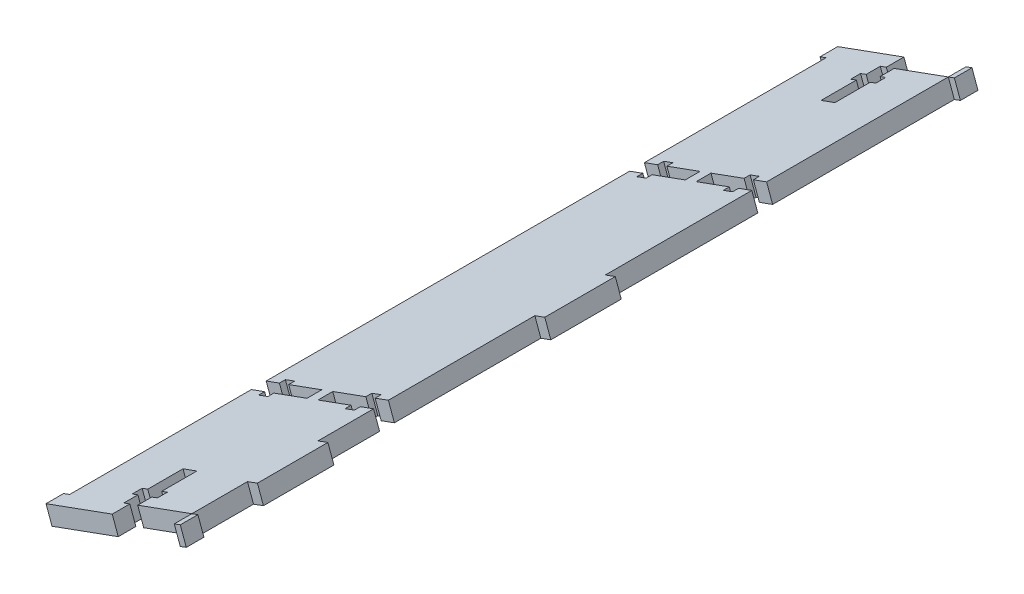
from build123d import *

# Parameters (mm, degrees)
BOSS_EXTRUDE1_DEPTH = 214.686455
CUT_EXTRUDE3_DEPTH  = 17.853621588
SKETCH5_W           = 20
SKETCH5_H           = 5
SKETCH5_W_2         = 1.823440518
SKETCH5_W_3         = 3
SKETCH5_H_2         = 20
BOSS_EXTRUDE2_DEPTH = 5


with BuildPart() as part:
    # Sketch2 → Boss-Extrude1 (new body)
    with BuildSketch(Plane.XY.offset(4.949356739)):
        Polygon((-52.961538618, -36.862052104), (-51.252736373, -41.56098761), (-85.936742732, -54.174080058), (-87.645544977, -49.475144552), align=None)
    extrude(amount=BOSS_EXTRUDE1_DEPTH)

    # Sketch4 → Cut-Extrude3 (cut, through all)
    with BuildSketch(Plane(origin=(7.362313595, -20.245196221, 0), x_dir=(-0.939787101, -0.341760449, 0), z_dir=(0.341760449, -0.939787101, 0))):
        Polygon((78.723681295, -4.949356739), (82.923681295, -4.949356739), (82.923681295, -8.949356739), (84.623681295, -8.949356739), (84.623681295, -11.749356739), (82.923681295, -11.749356739), (82.923681295, -21.749356739), (78.723681295, -21.749356739), (78.723681295, -11.749356739), (77.023681295, -11.749356739), (77.023681295, -8.949356739), (78.723681295, -8.949356739), align=None)
        Polygon((62.37056233, -60.720970532), (62.37056233, -56.520970532), (66.37056233, -56.520970532), (66.37056233, -54.820970532), (69.17056233, -54.820970532), (69.17056233, -56.520970532), (79.17056233, -56.520970532), (79.17056233, -60.720970532), (69.17056233, -60.720970532), (69.17056233, -62.420970532), (66.37056233, -62.420970532), (66.37056233, -60.720970532), align=None)
        Polygon((82.923681295, -219.635811913), (78.723681295, -219.635811913), (78.723681295, -215.635811913), (77.023681295, -215.635811913), (77.023681295, -212.835811913), (78.723681295, -212.835811913), (78.723681295, -202.835811913), (82.923681295, -202.835811913), (82.923681295, -212.835811913), (84.623681295, -212.835811913), (84.623681295, -215.635811913), (82.923681295, -215.635811913), align=None)
        Polygon((66.37056233, -168.064198119), (66.37056233, -169.764198119), (69.17056233, -169.764198119), (69.17056233, -168.064198119), (79.17056233, -168.064198119), (79.17056233, -163.864198119), (69.17056233, -163.864198119), (69.17056233, -162.164198119), (66.37056233, -162.164198119), (66.37056233, -163.864198119), (62.37056233, -163.864198119), (62.37056233, -168.064198119), align=None)
        Polygon((99.276800261, -163.864198119), (99.276800261, -168.064198119), (95.276800261, -168.064198119), (95.276800261, -169.764198119), (92.476800261, -169.764198119), (92.476800261, -168.064198119), (82.476800261, -168.064198119), (82.476800261, -163.864198119), (92.476800261, -163.864198119), (92.476800261, -162.164198119), (95.276800261, -162.164198119), (95.276800261, -163.864198119), align=None)
        Polygon((95.276800261, -56.520970532), (95.276800261, -54.820970532), (92.476800261, -54.820970532), (92.476800261, -56.520970532), (82.476800261, -56.520970532), (82.476800261, -60.720970532), (92.476800261, -60.720970532), (92.476800261, -62.420970532), (95.276800261, -62.420970532), (95.276800261, -60.720970532), (99.276800261, -60.720970532), (99.276800261, -56.520970532), align=None)
    extrude(amount=-CUT_EXTRUDE3_DEPTH, mode=Mode.SUBTRACT)

    # Sketch5 → Boss-Extrude2 (add)
    with BuildSketch(Plane(origin=(7.362313595, -20.245196221, 0), x_dir=(0.939787101, 0.341760449, 0), z_dir=(0.341760449, -0.939787101, 0))):
        with Locations((-91.100240778, 222.135811913)):
            Rectangle(SKETCH5_W, SKETCH5_H)
        with Locations((-61.458842071, 2.449356739)):
            Rectangle(SKETCH5_W_2, SKETCH5_H)
        with Locations((-60.87056233, 112.292584326)):
            Rectangle(SKETCH5_W_3, SKETCH5_H_2)
        with Locations((-60.87056233, 193.850005016)):
            Rectangle(SKETCH5_W_3, SKETCH5_H_2)
        with Locations((-61.458842071, 222.135811913)):
            Rectangle(SKETCH5_W_2, SKETCH5_H)
        with Locations((-91.100240778, 2.449356739)):
            Rectangle(SKETCH5_W, SKETCH5_H)
    extrude(amount=-BOSS_EXTRUDE2_DEPTH)


solid = part.part
